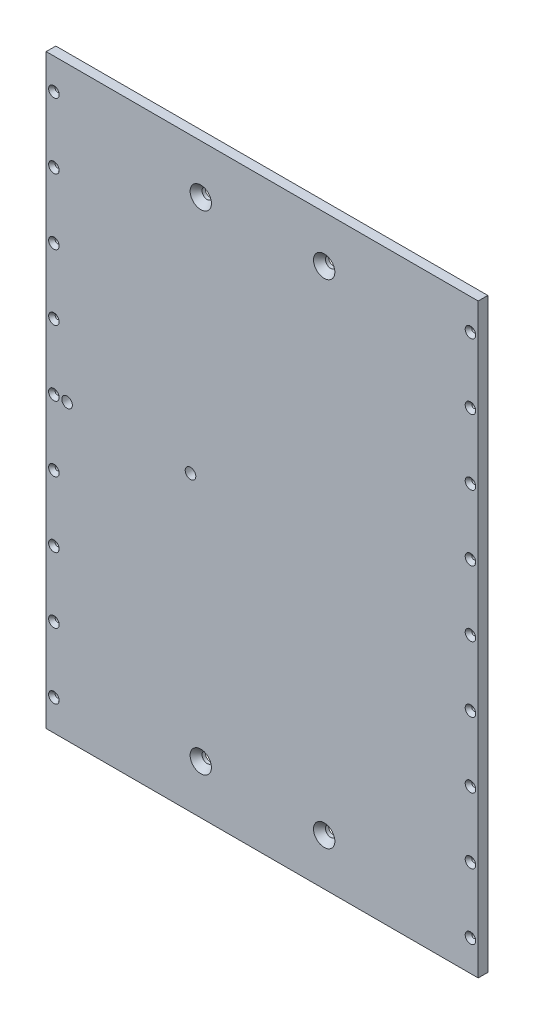
from build123d import *

# Parameters (mm, degrees)
SKETCH1_W                                         = 355.6
SKETCH1_H                                         = 482.6
EXTRUDE1_DEPTH                                    = 7.9375
F_5_16_CLEARANCE_HOLE1_D                          = 8.72998
F_5_16_CLEARANCE_HOLE1_DEPTH                      = 7.9375
CSK_FOR_5_16_FLAT_HEAD_SOCKET_CAP_SC_2_COUNT      = 2
CSK_FOR_5_16_FLAT_HEAD_SOCKET_CAP_SC_2_PITCH      = 405.637419891
CSK_FOR_5_16_FLAT_HEAD_SOCKET_CAP_SC_3_COUNT      = 2
CSK_FOR_5_16_FLAT_HEAD_SOCKET_CAP_SC_3_PITCH      = 101.6
CSK_FOR_5_16_FLAT_HEAD_SOCKET_CAP_SC_4_COUNT      = 2
CSK_FOR_5_16_FLAT_HEAD_SOCKET_CAP_SC_4_PITCH      = 416.444177142
CSK_FOR_6_FLAT_HEAD_SOCKET_CAP_SCREW1_D           = 3.6576
CSK_FOR_6_FLAT_HEAD_SOCKET_CAP_SCREW1_DEPTH       = 7.938008
CSK_FOR_6_FLAT_HEAD_SOCKET_CAP_SCREW1_CSINK_D     = 8.6809834
CSK_FOR_6_FLAT_HEAD_SOCKET_CAP_SCREW1_CSINK_ANGLE = 82
CSK_FOR_6_FLAT_HEAD_SOCKET_CAP_SCREW1_TIP         = 1.0988539


with BuildPart() as part:
    # Sketch1 → Extrude1 (new body)
    with BuildSketch(Plane.XY):
        Rectangle(SKETCH1_W, SKETCH1_H)
    extrude(amount=EXTRUDE1_DEPTH)

    # 5/16 Clearance Hole1
    with Locations(Plane(origin=(0, 0, 0), x_dir=(-1, 0, 0), z_dir=(0, 0, -1))):
        with Locations((59.004201824, 0), (160.604201824, 0)):
            Hole(F_5_16_CLEARANCE_HOLE1_D / 2, depth=F_5_16_CLEARANCE_HOLE1_DEPTH)

    # Sketch12 → CSK for 5/16 Flat Head Socket Cap Screw1 (revolve, cut)
    with BuildSketch(Plane(origin=(51.036073032, 202.818709946, 7.9375), x_dir=(0, -1, 0), z_dir=(1, 0, 0))):
        Polygon((0, 0), (0, 7.9375), (4.2164, 7.9375), (4.2164, 5.241529063), (8.7727917, 0), align=None)
    csk_for_5_16_flat_head_socket_cap_screw1 = revolve(axis=Axis((51.036073032, 202.818709946, 14.2875), (0, 0, -1)), mode=Mode.SUBTRACT)

    # CSK for 5_16 Flat Head Socket Cap Sc 2: CSK for 5/16 Flat Head Socket Cap Screw1 ×2
    with Locations(*[(0, -i * CSK_FOR_5_16_FLAT_HEAD_SOCKET_CAP_SC_2_PITCH, 0) for i in range(1, CSK_FOR_5_16_FLAT_HEAD_SOCKET_CAP_SC_2_COUNT)]):
        add(csk_for_5_16_flat_head_socket_cap_screw1, mode=Mode.SUBTRACT)

    # CSK for 5_16 Flat Head Socket Cap Sc 3: CSK for 5/16 Flat Head Socket Cap Screw1 ×2
    with Locations(*[Vector(-0.999847695, -0.017452406, 0) * (i * CSK_FOR_5_16_FLAT_HEAD_SOCKET_CAP_SC_3_PITCH) for i in range(1, CSK_FOR_5_16_FLAT_HEAD_SOCKET_CAP_SC_3_COUNT)]):
        add(csk_for_5_16_flat_head_socket_cap_screw1, mode=Mode.SUBTRACT)

    # CSK for 5_16 Flat Head Socket Cap Sc 4: CSK for 5/16 Flat Head Socket Cap Screw1 ×2
    with Locations(*[Vector(-0.243933116, -0.969792058, 0) * (i * CSK_FOR_5_16_FLAT_HEAD_SOCKET_CAP_SC_4_PITCH) for i in range(1, CSK_FOR_5_16_FLAT_HEAD_SOCKET_CAP_SC_4_COUNT)]):
        add(csk_for_5_16_flat_head_socket_cap_screw1, mode=Mode.SUBTRACT)

    # CSK for #6 Flat Head Socket Cap Screw1
    with Locations(Plane.XY.offset(7.9375)):
        with Locations((-171.45, -215.9), (171.45, -215.9), (171.45, -161.925), (-171.45, -161.925), (171.45, -107.95), (-171.45, -107.95), (171.45, -53.975), (-171.45, -53.975), (171.45, 0), (-171.45, 0), (171.45, 53.975), (-171.45, 53.975), (171.45, 107.95), (-171.45, 107.95), (171.45, 161.925), (-171.45, 161.925), (171.45, 215.9), (-171.45, 215.9)):
            CounterSinkHole(CSK_FOR_6_FLAT_HEAD_SOCKET_CAP_SCREW1_D / 2, CSK_FOR_6_FLAT_HEAD_SOCKET_CAP_SCREW1_CSINK_D / 2, depth=CSK_FOR_6_FLAT_HEAD_SOCKET_CAP_SCREW1_DEPTH, counter_sink_angle=CSK_FOR_6_FLAT_HEAD_SOCKET_CAP_SCREW1_CSINK_ANGLE)
            with Locations((0, 0, -(CSK_FOR_6_FLAT_HEAD_SOCKET_CAP_SCREW1_DEPTH + CSK_FOR_6_FLAT_HEAD_SOCKET_CAP_SCREW1_TIP / 2))):  # 118° drill point
                Cone(0, CSK_FOR_6_FLAT_HEAD_SOCKET_CAP_SCREW1_D / 2, CSK_FOR_6_FLAT_HEAD_SOCKET_CAP_SCREW1_TIP, mode=Mode.SUBTRACT)


solid = part.part
